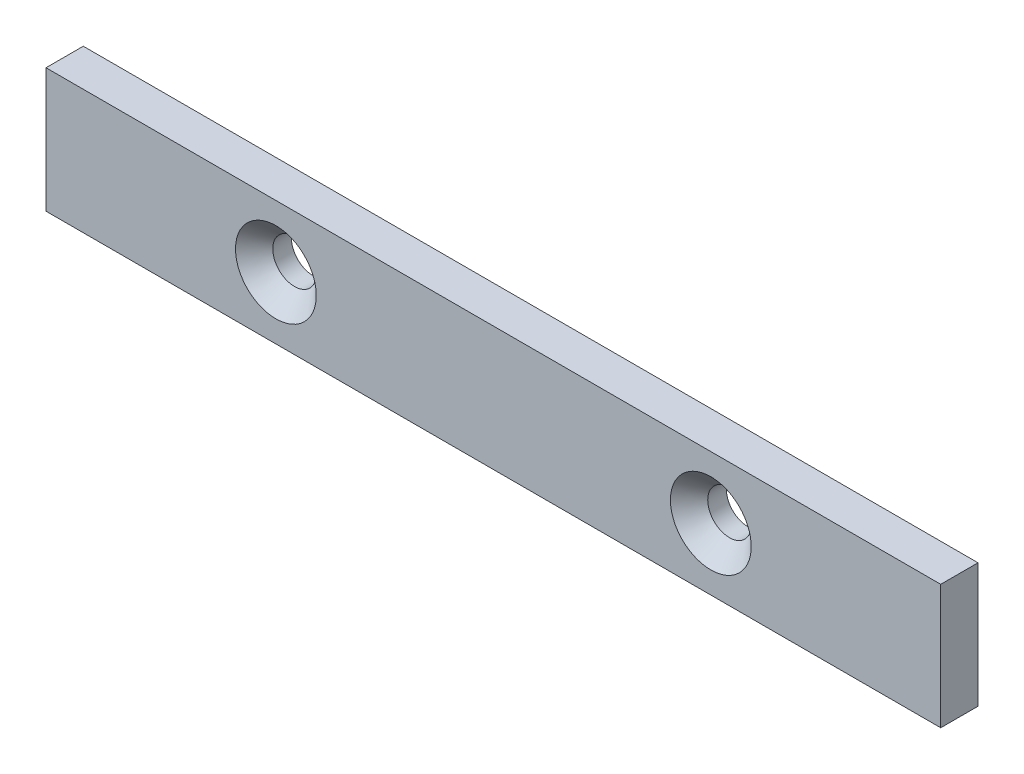
from build123d import *

# Parameters (mm, degrees)
SKETCH1_W           = 144
SKETCH1_H           = 20
SKETCH1_R           = 3.5
BOSS_EXTRUDE1_DEPTH = 3
CHAMFER1_SIZE       = 3


with BuildPart() as part:
    # Sketch1 → Boss-Extrude1 (new body, symmetric)
    with BuildSketch(Plane.XY):
        Rectangle(SKETCH1_W, SKETCH1_H)
        with Locations((35, 0)):
            Circle(SKETCH1_R, mode=Mode.SUBTRACT)
        with Locations((-35, 0)):
            Circle(SKETCH1_R, mode=Mode.SUBTRACT)
    extrude(amount=BOSS_EXTRUDE1_DEPTH, both=True)

    # Chamfer1
    chamfer1_edges = [part.edges().sort_by_distance(p)[0] for p in [
        (31.5, 0, 3),
        (-38.5, 0, 3),
    ]]
    chamfer(chamfer1_edges, length=CHAMFER1_SIZE)


solid = part.part
